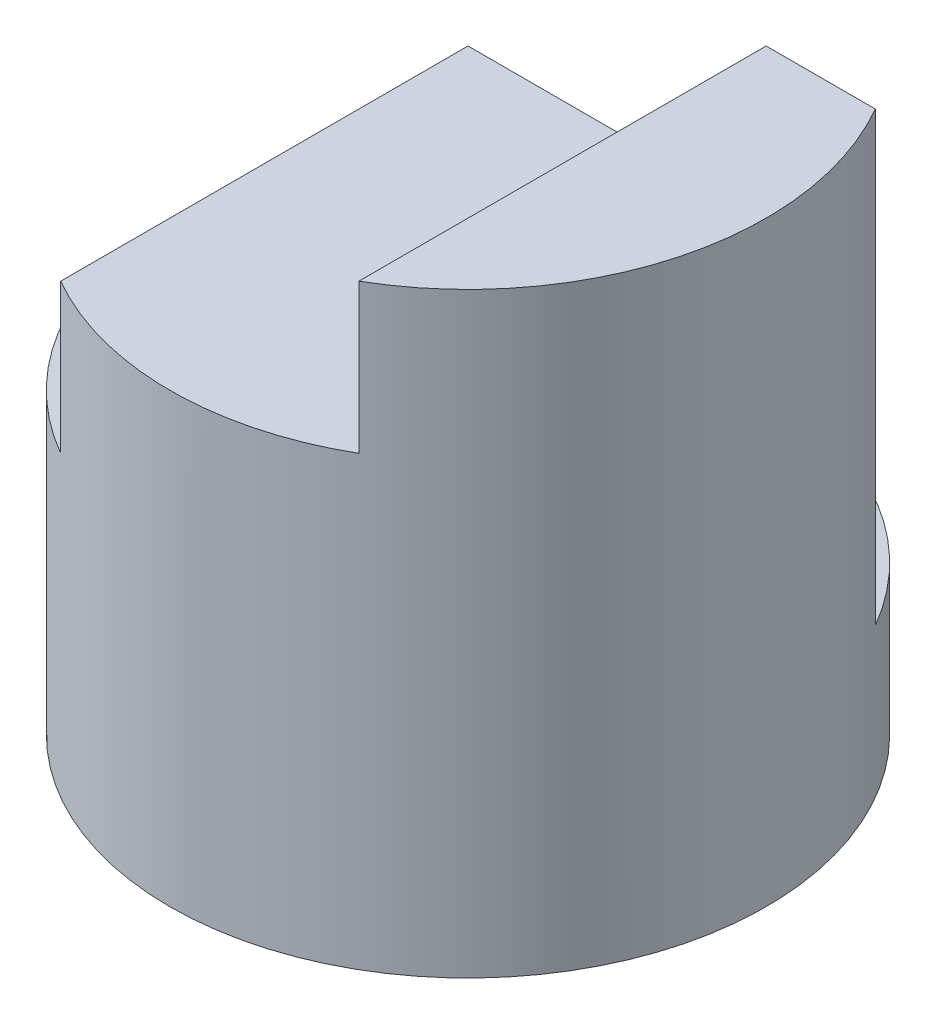
from build123d import *

# Parameters (mm, degrees)
SKETCH1_R           = 2
BOSS_EXTRUDE1_DEPTH = 4
CUT_EXTRUDE1_DEPTH  = 2
CUT_EXTRUDE2_DEPTH  = 3


with BuildPart() as part:
    # Sketch1 → Boss-Extrude1 (new body)
    with BuildSketch(Plane(origin=(0, 0, 0), x_dir=(1, 0, 0), z_dir=(0, 1, 0))):
        Circle(SKETCH1_R)
    extrude(amount=BOSS_EXTRUDE1_DEPTH)

    # Sketch2 → Cut-Extrude1 (cut, symmetric)
    with BuildSketch(Plane.XY):
        Polygon((1, 4), (1, 3), (-1, 3), (-1, 2), (-2, 2), (-2, 4), align=None)
    extrude(amount=CUT_EXTRUDE1_DEPTH, both=True, mode=Mode.SUBTRACT)

    # Sketch3 → Cut-Extrude2 (cut)
    with BuildSketch(Plane(origin=(0, 4, 0), x_dir=(1, 0, 0), z_dir=(0, 1, 0))):
        with BuildLine():
            Line((-1.732050808, 1), (1.732050808, 1))
            ThreePointArc((1.732050808, 1), (0, 2), (-1.732050808, 1))
        make_face()
    extrude(amount=-CUT_EXTRUDE2_DEPTH, mode=Mode.SUBTRACT)


solid = part.part
